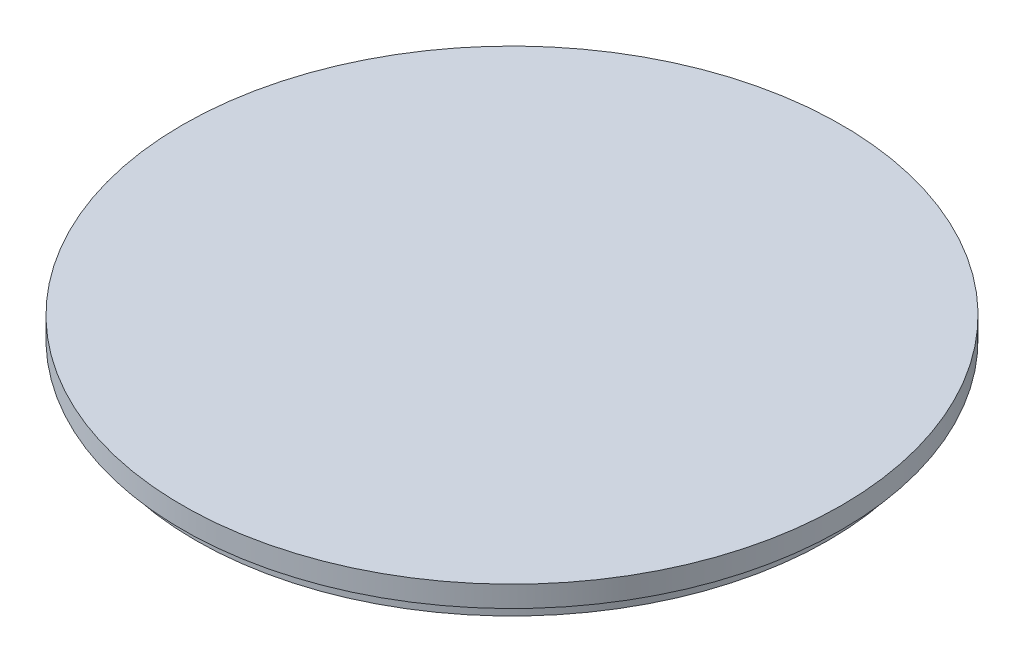
from build123d import *


with BuildPart() as part:
    # Sketch1 → Revolve1 (revolve)
    with BuildSketch(Plane.XY):
        Polygon((0, 0), (0, 4), (-62.5, 4), (-62.5, 0), (-60, 0), (-60, -3), (-58.267949192, 0), align=None)
    revolve(axis=Axis((0, 0, 0), (0, 1, 0)))


solid = part.part
